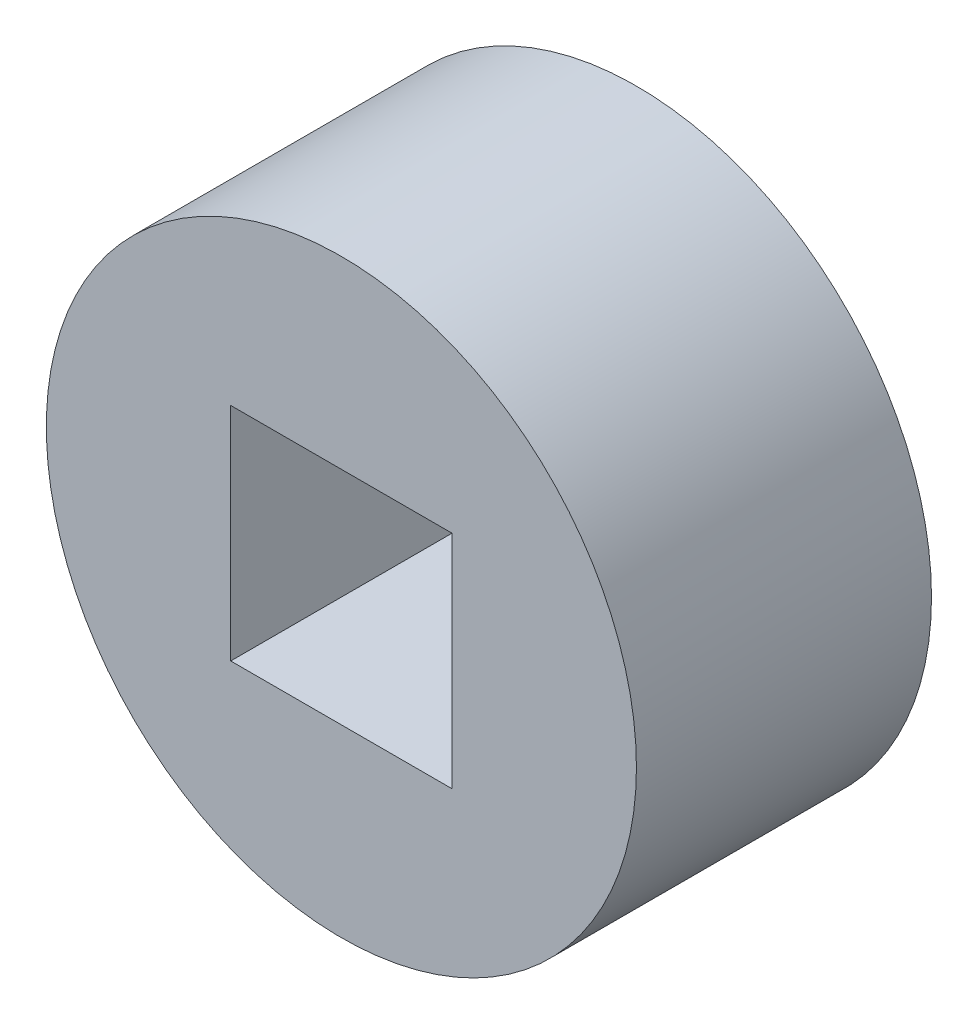
from build123d import *

# Parameters (mm, degrees)
SKETCH_1_R      = 4
SKETCH_1_W      = 3
SKETCH_1_H      = 3
EXTRUDE_1_DEPTH = 4


with BuildPart() as part:
    # 草图1 → 凸台-拉伸1 (new body)
    with BuildSketch(Plane.XY):
        Circle(SKETCH_1_R)
        Rectangle(SKETCH_1_W, SKETCH_1_H, mode=Mode.SUBTRACT)
    extrude(amount=EXTRUDE_1_DEPTH)


solid = part.part
